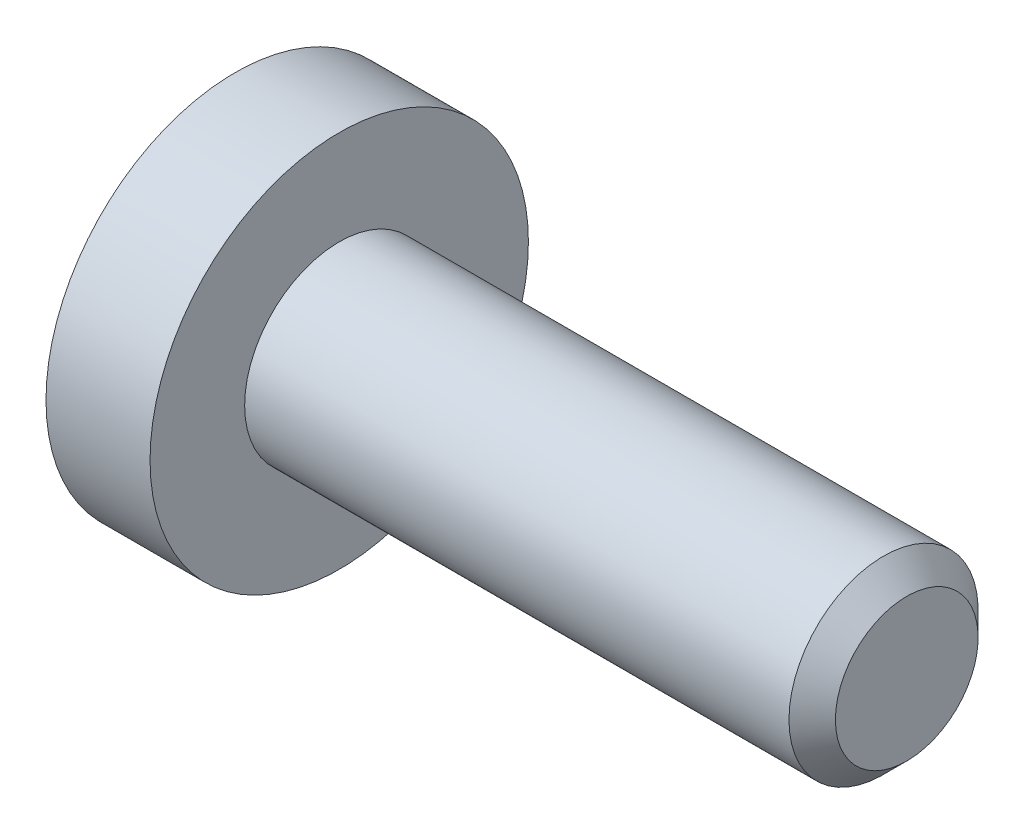
from build123d import *

# Parameters (mm, degrees)
CUT_EXTRUDE1_DEPTH = 1.2


with BuildPart() as part:
    # Sketch1 → Revolve1 (revolve)
    with BuildSketch(Plane.XY):
        Polygon((-1.1, 0), (-1.1, 2), (0, 2), (0, 1), (5.7545, 1), (6, 0.7545), (6, 0), align=None)
    revolve(axis=Axis((6, 0, 0), (-1, 0, 0)))

    # Sketch2 → Cut-Extrude1 (cut)
    with BuildSketch(Plane(origin=(-1.1, 0, 0), x_dir=(0, 0, -1), z_dir=(1, 0, 0))):
        Polygon((-0.65, -0.375277675), (0, -0.75055535), (0.65, -0.375277675), (0.65, 0.375277675), (0, 0.75055535), (-0.65, 0.375277675), align=None)
    extrude(amount=CUT_EXTRUDE1_DEPTH, mode=Mode.SUBTRACT)


solid = part.part
